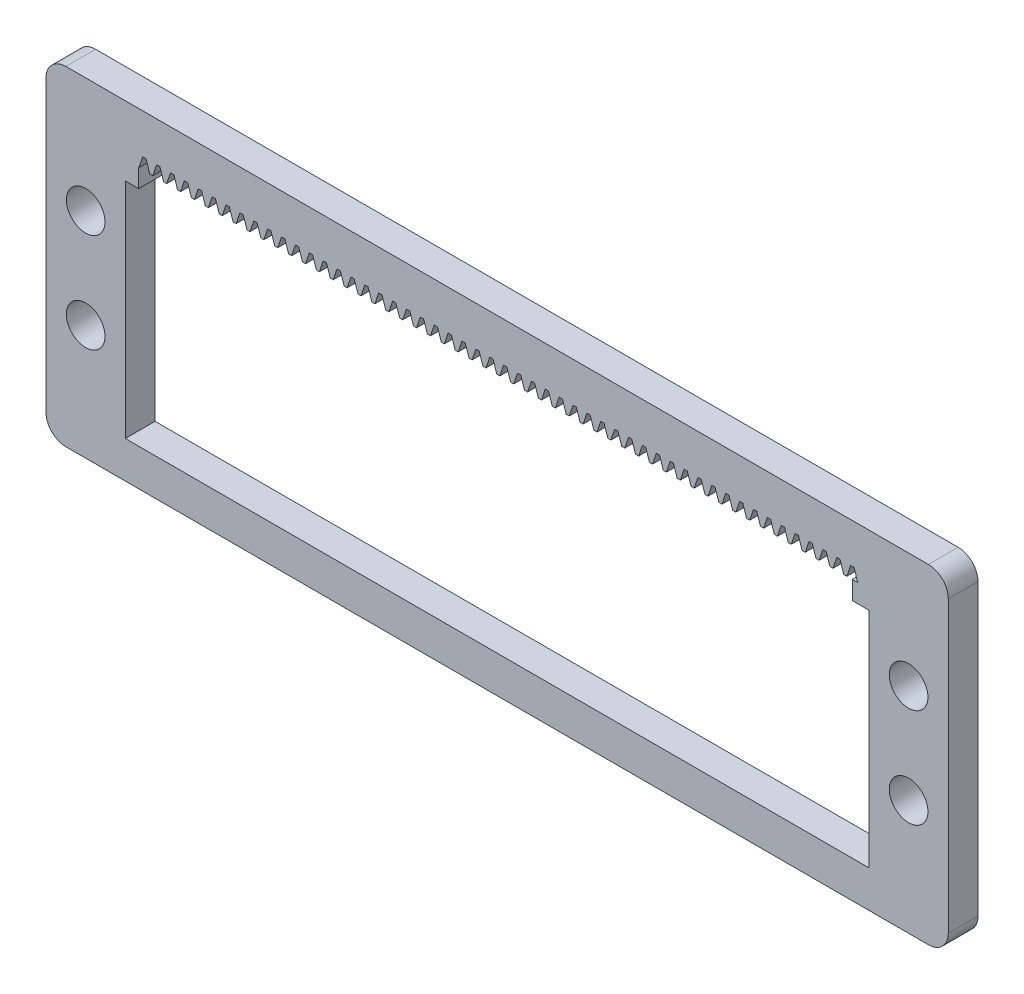
from build123d import *

# Parameters (mm, degrees)
BOSS_EXTRUDE1_DEPTH = 3
SKETCH2_W           = 75
SKETCH2_H           = 22.5
CUT_EXTRUDE1_DEPTH  = 4
SKETCH3_W           = 71.97
SKETCH3_H           = 1.85
CUT_EXTRUDE2_DEPTH  = 4
CUT_EXTRUDE4_DEPTH  = 4
LPATTERN1_COUNT     = 52
LPATTERN1_PITCH     = 1.4
SKETCH5_R           = 1.95
CUT_EXTRUDE5_DEPTH  = 10


with BuildPart() as part:
    # Sketch1 → Boss-Extrude1 (new body)
    with BuildSketch(Plane.XY):
        with BuildLine():
            Line((2, 0), (89, 0))
            ThreePointArc((89, 0), (90.414213562, -0.585786438), (91, -2))
            Line((91, -2), (91, -31.22))
            ThreePointArc((91, -31.22), (90.414213562, -32.634213562), (89, -33.22))
            Line((89, -33.22), (2, -33.22))
            ThreePointArc((2, -33.22), (0.585786438, -32.634213562), (0, -31.22))
            Line((0, -31.22), (0, -2))
            ThreePointArc((0, -2), (0.585786438, -0.585786438), (2, 0))
        make_face()
    extrude(amount=BOSS_EXTRUDE1_DEPTH)

    # Sketch2 → Cut-Extrude1 (cut, through all)
    with BuildSketch(Plane.XY.offset(3)):
        with Locations((45.5, -18.25)):
            Rectangle(SKETCH2_W, SKETCH2_H)
    extrude(amount=-CUT_EXTRUDE1_DEPTH, mode=Mode.SUBTRACT)

    # Sketch3 → Cut-Extrude2 (cut, through all)
    with BuildSketch(Plane.XY.offset(3)):
        with Locations((45.335, -6.075)):
            Rectangle(SKETCH3_W, SKETCH3_H)
    extrude(amount=-CUT_EXTRUDE2_DEPTH, mode=Mode.SUBTRACT)

    # Sketch4 → Cut-Extrude4 (cut, through all)
    with BuildSketch(Plane.XY.offset(3)):
        Polygon((81.485, -4.011755738), (81.865, -5.15), (80.775, -5.15), (81.155, -4.011755738), align=None)
    cut_extrude4 = extrude(amount=-CUT_EXTRUDE4_DEPTH, mode=Mode.SUBTRACT)

    # LPattern1: Cut-Extrude4 ×52
    with Locations(*[(-i * LPATTERN1_PITCH, 0, 0) for i in range(1, LPATTERN1_COUNT)]):
        add(cut_extrude4, mode=Mode.SUBTRACT)

    # Sketch5 → Cut-Extrude5 (cut)
    with BuildSketch(Plane.XY.offset(3)):
        with Locations((4, -11.61)):
            Circle(SKETCH5_R)
        with Locations((4, -21.61)):
            Circle(SKETCH5_R)
        with Locations((87, -11.61)):
            Circle(SKETCH5_R)
        with Locations((87, -21.61)):
            Circle(SKETCH5_R)
    extrude(amount=-CUT_EXTRUDE5_DEPTH, mode=Mode.SUBTRACT)


solid = part.part
